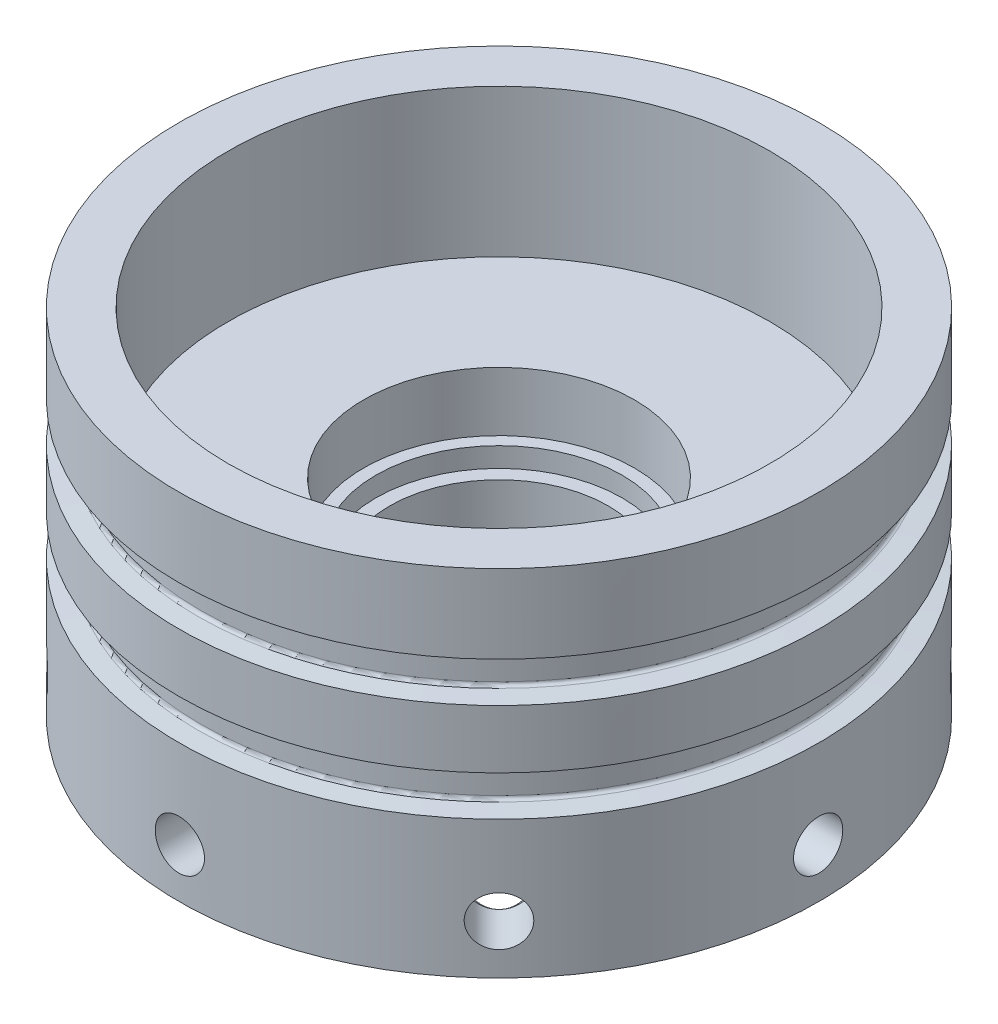
from build123d import *

# Parameters (mm, degrees)
LPATTERN1_COUNT   = 2
LPATTERN1_PITCH   = 12.7
CIRPATTERN1_COUNT = 8


with BuildPart() as part:
    # Sketch1 → Revolve1 (revolve)
    with BuildSketch(Plane.XY):
        Polygon((-41.275, 13.97), (-41.275, 45.72), (-34.925, 45.72), (-34.925, 26.67), (-17.4625, 26.67), (-17.4625, 19.05), (-15.875, 19.05), (-15.875, 16.51), (-14.0890625, 16.51), (-14.0890625, 0), (-18.5340625, 0), (-18.5340625, 13.97), (-34.925, 13.97), (-34.925, 0), (-41.275, 0), align=None)
    revolve(axis=Axis((0, 0, 0), (0, 1, 0)))

    # Sketch3 → Groove for AS 568-234_ O-Ring1 (revolve, cut)
    with BuildSketch(Plane(origin=(0, 0, 0), x_dir=(0, 0, -1), z_dir=(-1, 0, 0))):
        with BuildLine():
            Line((38.861359272, -30.6451), (41.3639, -30.426156056))
            Line((41.3639, -30.426156056), (41.3639, -35.613843944))
            Line((41.3639, -35.613843944), (38.861359272, -35.3949))
            ThreePointArc((38.861359272, -35.3949), (38.572380224, -35.252391304), (38.4556, -34.952091457))
            Line((38.4556, -34.952091457), (38.4556, -31.087908543))
            ThreePointArc((38.4556, -31.087908543), (38.572380224, -30.787608696), (38.861359272, -30.6451))
        make_face()
    groove_for_as_568_234_o_ring1 = revolve(axis=Axis((0, -50, 0), (0, 1, 0)), mode=Mode.SUBTRACT)

    # LPattern1: Groove for AS 568-234_ O-Ring1 ×2
    with Locations(*[(0, -i * LPATTERN1_PITCH, 0) for i in range(1, LPATTERN1_COUNT)]):
        add(groove_for_as_568_234_o_ring1, mode=Mode.SUBTRACT)

    # Sketch5 → 1_4 _0.25_ Diameter Hole1 (revolve, cut)
    with BuildSketch(Plane(origin=(41.275, 6.35, 0), x_dir=(0, 0, -1), z_dir=(0, 1, 0))):
        Polygon((0, 0), (0, 8.257732465), (3.175, 6.35), (3.175, 0), align=None)
    f_1_4_0_25_diameter_hole1 = revolve(axis=Axis((47.625, 6.35, 0), (-1, 0, 0)), mode=Mode.SUBTRACT)

    # CirPattern1: 1_4 _0.25_ Diameter Hole1 ×8 about axis
    cirpattern1_axis = Axis((0, -2.286, 0), (0, 1, 0))
    for i in range(1, CIRPATTERN1_COUNT):
        add(f_1_4_0_25_diameter_hole1.rotate(cirpattern1_axis, i * 360 / CIRPATTERN1_COUNT), mode=Mode.SUBTRACT)


solid = part.part
